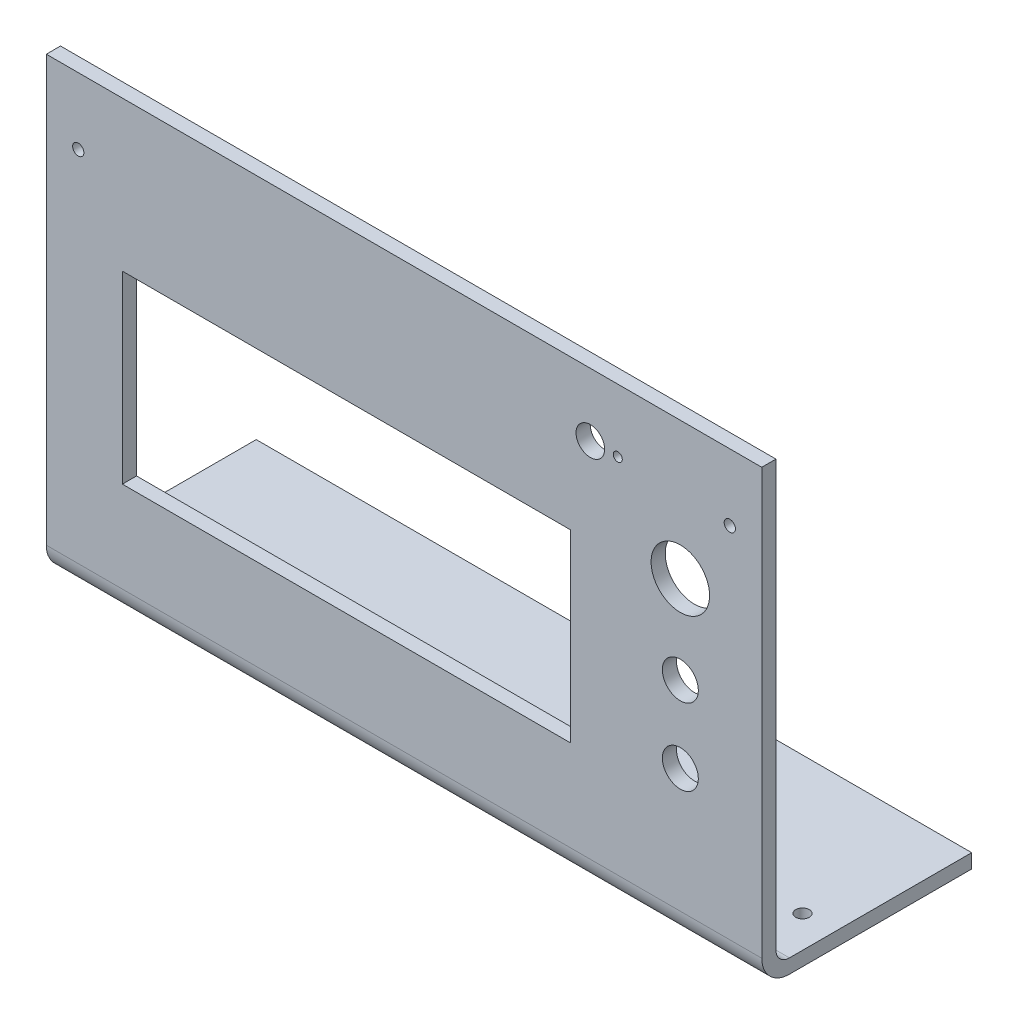
from build123d import *

# Parameters (mm, degrees)
SKETCH22_W          = 159
SKETCH22_H          = 90
SKETCH22_R          = 4
SKETCH22_R_2        = 6.5
SKETCH22_W_2        = 99.6
SKETCH22_H_2        = 41
BOSS_EXTRUDE1_DEPTH = 3.15
BOSS_EXTRUDE2_DEPTH = 159
SKETCH25_R          = 1.25
CUT_EXTRUDE1_DEPTH  = 47.65
SKETCH26_R          = 1.5
CUT_EXTRUDE2_DEPTH  = 101.65
SKETCH28_R          = 3.175
SKETCH28_R_2        = 1
CUT_EXTRUDE3_DEPTH  = 47.65


with BuildPart() as part:
    # Sketch22 → Boss-Extrude1 (new body)
    with BuildSketch(Plane.XY):
        with Locations((-61.4, -14.5)):
            Rectangle(SKETCH22_W, SKETCH22_H)
        with Locations((0, -19.5)):
            Circle(SKETCH22_R, mode=Mode.SUBTRACT)
        with Locations((0, -36.5)):
            Circle(SKETCH22_R, mode=Mode.SUBTRACT)
        Circle(SKETCH22_R_2, mode=Mode.SUBTRACT)
        with Locations((-74.2, -23.3)):
            Rectangle(SKETCH22_W_2, SKETCH22_H_2, mode=Mode.SUBTRACT)
    extrude(amount=BOSS_EXTRUDE1_DEPTH)

    # Sketch23 → Boss-Extrude2 (add)
    with BuildSketch(Plane.ZY.offset(140.9)):
        with BuildLine():
            Line((0, -59.5), (3.15, -59.5))
            Line((3.15, -59.5), (3.15, -64))
            ThreePointArc((3.15, -64), (1.348706704, -68.348706704), (-3, -70.15))
            Line((-3, -70.15), (-43.5, -70.15))
            Line((-43.5, -70.15), (-43.5, -67))
            Line((-43.5, -67), (-3, -67))
            ThreePointArc((-3, -67), (-0.878679656, -66.121320344), (0, -64))
            Line((0, -64), (0, -59.5))
        make_face()
    extrude(amount=-BOSS_EXTRUDE2_DEPTH)

    # Sketch25 → Cut-Extrude1 (cut, through all)
    with BuildSketch(Plane.XY.offset(3.15)):
        with Locations((-133.8, 15.7)):
            Circle(SKETCH25_R)
        with Locations((11, 15.7)):
            Circle(SKETCH25_R)
    extrude(amount=-CUT_EXTRUDE1_DEPTH, mode=Mode.SUBTRACT)

    # Sketch26 → Cut-Extrude2 (cut, through all)
    with BuildSketch(Plane.XZ.offset(70.15)):
        with Locations((-133.8, -13)):
            Circle(SKETCH26_R)
        with Locations((11, -13)):
            Circle(SKETCH26_R)
    extrude(amount=-CUT_EXTRUDE2_DEPTH, mode=Mode.SUBTRACT)

    # Sketch28 → Cut-Extrude3 (cut, through all)
    with BuildSketch(Plane.XY.offset(3.15)):
        with Locations((-20, 16.5)):
            Circle(SKETCH28_R)
        with Locations((-13.9, 16.5)):
            Circle(SKETCH28_R_2)
    extrude(amount=-CUT_EXTRUDE3_DEPTH, mode=Mode.SUBTRACT)


solid = part.part
